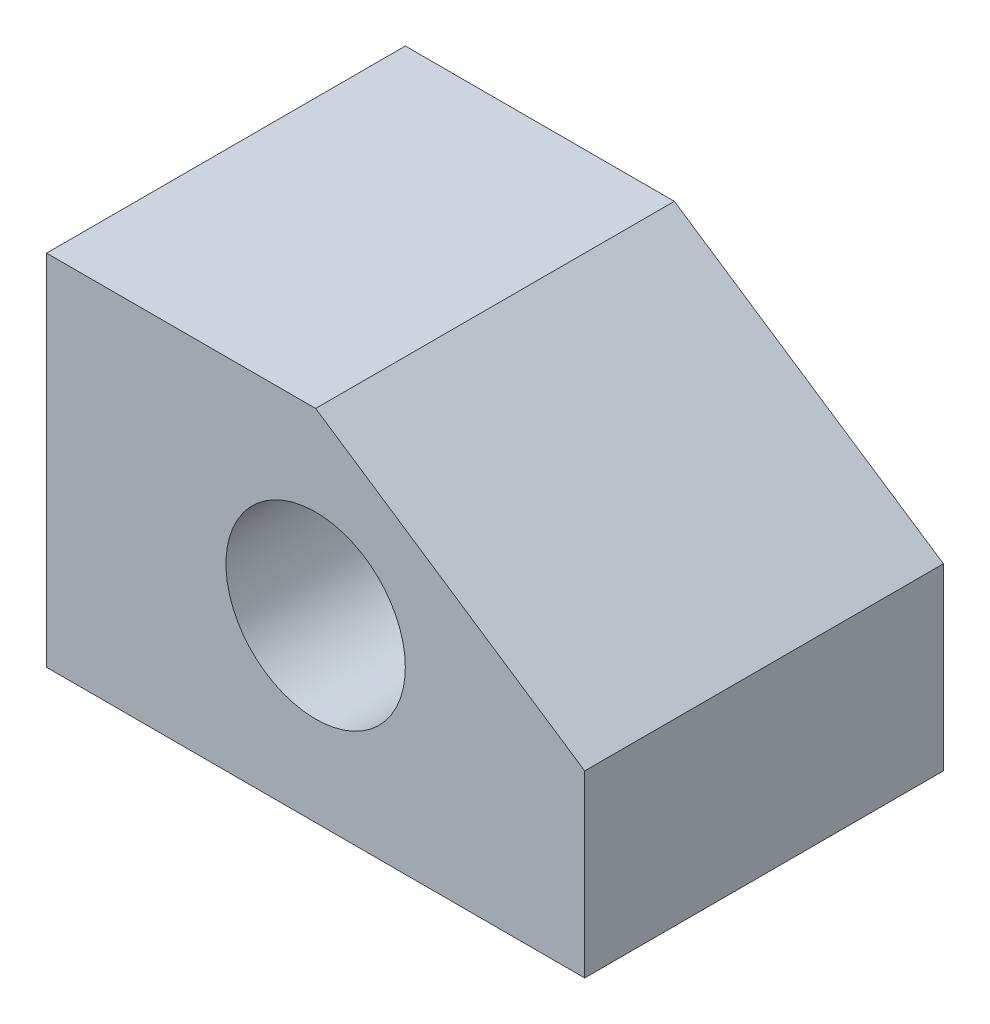
from build123d import *

# Parameters (mm, degrees)
BOSS_EXTRUDE1_DEPTH = 20
SKETCH7_R           = 5
CUT_EXTRUDE1_DEPTH  = 20


with BuildPart() as part:
    # Sketch2 → Boss-Extrude1 (new body)
    with BuildSketch(Plane.XY):
        Polygon((0, 0), (30, 0), (30, 10), (15, 20), (0, 20), align=None)
    extrude(amount=-BOSS_EXTRUDE1_DEPTH)

    # Sketch7 → Cut-Extrude1 (cut)
    with BuildSketch(Plane.XY):
        with Locations((15, 10)):
            Circle(SKETCH7_R)
    extrude(amount=-CUT_EXTRUDE1_DEPTH, mode=Mode.SUBTRACT)


solid = part.part
